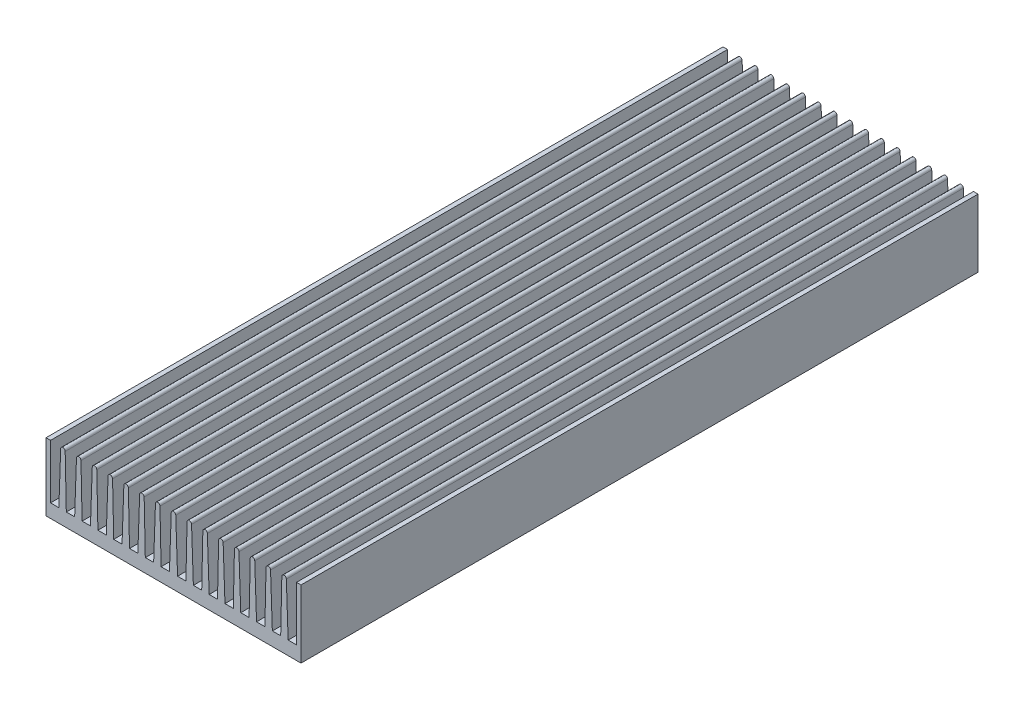
from build123d import *

# Parameters (mm, degrees)
RESSALTO_EXTRUS_O1_DEPTH = 300


with BuildPart() as part:
    # Esboço1 → Ressalto-extrusão1 (new body)
    with BuildSketch(Plane.XY):
        with BuildLine():
            Line((0, 0), (-113, 0))
            Line((-113, 0), (-113, 30))
            Line((-113, 30), (-111, 30))
            Line((-111, 30), (-111, 6))
            Line((-111, 6), (-107.3, 6))
            Line((-107.3, 6), (-106.5, 29))
            ThreePointArc((-106.5, 29), (-105.5, 30), (-104.5, 29))
            Line((-104.5, 29), (-104, 6))
            Line((-104, 6), (-100.3, 6))
            Line((-100.3, 6), (-99.5, 29))
            ThreePointArc((-99.5, 29), (-98.5, 30), (-97.5, 29))
            Line((-97.5, 29), (-97, 6))
            Line((-97, 6), (-93.3, 6))
            Line((-93.3, 6), (-92.5, 29))
            ThreePointArc((-92.5, 29), (-91.5, 30), (-90.5, 29))
            Line((-90.5, 29), (-90, 6))
            Line((-90, 6), (-86.3, 6))
            Line((-86.3, 6), (-85.5, 29))
            ThreePointArc((-85.5, 29), (-84.5, 30), (-83.5, 29))
            Line((-83.5, 29), (-83, 6))
            Line((-83, 6), (-79.3, 6))
            Line((-79.3, 6), (-78.5, 29))
            ThreePointArc((-78.5, 29), (-77.5, 30), (-76.5, 29))
            Line((-76.5, 29), (-76, 6))
            Line((-76, 6), (-72.3, 6))
            Line((-72.3, 6), (-71.5, 29))
            ThreePointArc((-71.5, 29), (-70.5, 30), (-69.5, 29))
            Line((-69.5, 29), (-69, 6))
            Line((-69, 6), (-65.3, 6))
            Line((-65.3, 6), (-64.5, 29))
            ThreePointArc((-64.5, 29), (-63.5, 30), (-62.5, 29))
            Line((-62.5, 29), (-62, 6))
            Line((-62, 6), (-58.3, 6))
            Line((-58.3, 6), (-57.5, 29))
            ThreePointArc((-57.5, 29), (-56.5, 30), (-55.5, 29))
            Line((-55.5, 29), (-54.7, 6))
            Line((-54.7, 6), (-51, 6))
            Line((-51, 6), (-50.5, 29))
            ThreePointArc((-50.5, 29), (-49.5, 30), (-48.5, 29))
            Line((-48.5, 29), (-47.7, 6))
            Line((-47.7, 6), (-44, 6))
            Line((-44, 6), (-43.5, 29))
            ThreePointArc((-43.5, 29), (-42.5, 30), (-41.5, 29))
            Line((-41.5, 29), (-40.7, 6))
            Line((-40.7, 6), (-37, 6))
            Line((-37, 6), (-36.5, 29))
            ThreePointArc((-36.5, 29), (-35.5, 30), (-34.5, 29))
            Line((-34.5, 29), (-33.7, 6))
            Line((-33.7, 6), (-30, 6))
            Line((-30, 6), (-29.5, 29))
            ThreePointArc((-29.5, 29), (-28.5, 30), (-27.5, 29))
            Line((-27.5, 29), (-26.7, 6))
            Line((-26.7, 6), (-23, 6))
            Line((-23, 6), (-22.5, 29))
            ThreePointArc((-22.5, 29), (-21.5, 30), (-20.5, 29))
            Line((-20.5, 29), (-19.7, 6))
            Line((-19.7, 6), (-16, 6))
            Line((-16, 6), (-15.5, 29))
            ThreePointArc((-15.5, 29), (-14.5, 30), (-13.5, 29))
            Line((-13.5, 29), (-12.7, 6))
            Line((-12.7, 6), (-9, 6))
            Line((-9, 6), (-8.5, 29))
            ThreePointArc((-8.5, 29), (-7.5, 30), (-6.5, 29))
            Line((-6.5, 29), (-5.7, 6))
            Line((-5.7, 6), (-2, 6))
            Line((-2, 6), (-2, 30))
            Line((-2, 30), (0, 30))
            Line((0, 30), (0, 0))
        make_face()
    extrude(amount=RESSALTO_EXTRUS_O1_DEPTH)


solid = part.part
